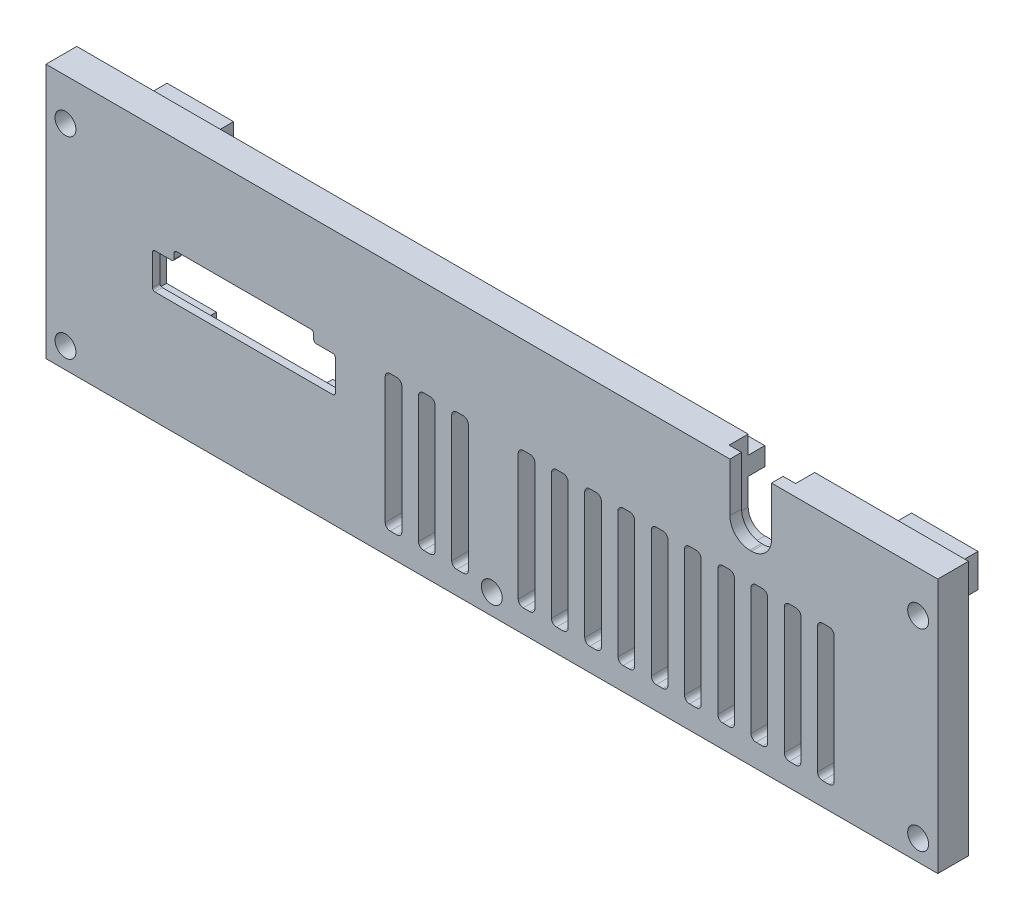
from build123d import *

# Parameters (mm, degrees)
SKETCH1_W                       = 136.2202
SKETCH1_H                       = 38.9636
BOSS_EXTRUDE1_DEPTH             = 4.699
CUT_EXTRUDE1_DEPTH              = 5.699
SKETCH3_W                       = 38.1
SKETCH3_H                       = 21.336
CUT_EXTRUDE3_DEPTH              = 3.556
M3_CLEARANCE_HOLE1_D            = 3.2
M3_CLEARANCE_HOLE1_DEPTH        = 4.826
SKETCH6_W                       = 10.16
SKETCH6_H                       = 5.08
BOSS_EXTRUDE3_DEPTH             = 7.62
BOSS_EXTRUDE3_DEPTH_BACK        = 4.699
SKETCH7_W                       = 109.1438
SKETCH7_H                       = 2.794
BOSS_EXTRUDE4_DEPTH             = 2.54
FILLET1_R                       = 2.54
TAP_DRILL_FOR_M3X0_5_TAP1_D     = 2.5
TAP_DRILL_FOR_M3X0_5_TAP1_DEPTH = 5.08
CUT_EXTRUDE4_DEPTH              = 13.319
CUT_EXTRUDE5_DEPTH              = 5.461
CUT_EXTRUDE8_DEPTH              = 5.699
SKETCH13_W                      = 38.1
SKETCH13_H                      = 21.336
BOSS_EXTRUDE5_DEPTH             = 3.556


with BuildPart() as part:
    # Sketch1 → Boss-Extrude1 (new body)
    with BuildSketch(Plane.XY):
        with Locations((68.1101, 19.4818)):
            Rectangle(SKETCH1_W, SKETCH1_H)
    extrude(amount=BOSS_EXTRUDE1_DEPTH)

    # Sketch2 → Cut-Extrude1 (cut, through all)
    with BuildSketch(Plane.XY.offset(4.699)):
        with BuildLine():
            Line((16.637, 17.152915383), (43.815, 17.152915383))
            ThreePointArc((43.815, 17.152915383), (44.084407684, 17.264507699), (44.196, 17.533915383))
            Line((44.196, 17.533915383), (44.196, 22.232915383))
            ThreePointArc((44.196, 22.232915383), (44.084407684, 22.502323067), (43.815, 22.613915383))
            Line((43.815, 22.613915383), (41.275, 22.613915383))
            ThreePointArc((41.275, 22.613915383), (41.005592316, 22.725507699), (40.894, 22.994915383))
            Line((40.894, 22.994915383), (40.894, 23.756915383))
            ThreePointArc((40.894, 23.756915383), (40.782407684, 24.026323067), (40.513, 24.137915383))
            Line((40.513, 24.137915383), (19.939, 24.137915383))
            ThreePointArc((19.939, 24.137915383), (19.669592316, 24.026323067), (19.558, 23.756915383))
            Line((19.558, 23.756915383), (19.558, 22.994915383))
            ThreePointArc((19.558, 22.994915383), (19.446407684, 22.725507699), (19.177, 22.613915383))
            Line((19.177, 22.613915383), (16.637, 22.613915383))
            ThreePointArc((16.637, 22.613915383), (16.367592316, 22.502323067), (16.256, 22.232915383))
            Line((16.256, 22.232915383), (16.256, 17.533915383))
            ThreePointArc((16.256, 17.533915383), (16.367592316, 17.264507699), (16.637, 17.152915383))
        make_face()
    extrude(amount=-CUT_EXTRUDE1_DEPTH, mode=Mode.SUBTRACT)

    # Sketch3 → Cut-Extrude3 (cut)
    with BuildSketch(Plane(origin=(0, 0, 0), x_dir=(-1, 0, 0), z_dir=(0, 0, -1))):
        with Locations((-30.226, 20.581915383)):
            Rectangle(SKETCH3_W, SKETCH3_H)
    extrude(amount=-CUT_EXTRUDE3_DEPTH, mode=Mode.SUBTRACT)

    # M3 Clearance Hole1
    with Locations(Plane.XY.offset(4.699)):
        with Locations((2.9718, 32.6136), (2.9718, 3.175), (68.0974, 3.175), (133.223, 32.6136), (133.223, 3.175)):
            Hole(M3_CLEARANCE_HOLE1_D / 2, depth=M3_CLEARANCE_HOLE1_DEPTH)

    # Sketch6 → Boss-Extrude3 (add, two sides)
    with BuildSketch(Plane(origin=(0, 0, 0), x_dir=(-1, 0, 0), z_dir=(0, 0, -1))) as boss_extrude3_sk:
        with Locations((-124.968, 30.8356)):
            Rectangle(SKETCH6_W, SKETCH6_H)
        with Locations((-11.2522, 30.8356)):
            Rectangle(SKETCH6_W, SKETCH6_H)
    extrude(amount=BOSS_EXTRUDE3_DEPTH)
    extrude(boss_extrude3_sk.sketch, amount=-BOSS_EXTRUDE3_DEPTH_BACK)

    # Sketch7 → Boss-Extrude4 (add)
    with BuildSketch(Plane(origin=(0, 0, 0), x_dir=(-1, 0, 0), z_dir=(0, 0, -1))):
        with Locations((-68.1101, 34.7726)):
            Rectangle(SKETCH7_W, SKETCH7_H)
    extrude(amount=BOSS_EXTRUDE4_DEPTH)

    # Fillet1
    fillet1_edges = [part.edges().sort_by_distance(p)[0] for p in [
        (14.9352, 33.3756, -2.54),
        (121.285, 33.3756, -2.54),
    ]]
    fillet(fillet1_edges, radius=FILLET1_R)

    # Tap Drill for M3x0.5 Tap1
    with Locations(Plane(origin=(0, 33.3756, 0), x_dir=(1, 0, 0), z_dir=(0, 1, 0))):
        with Locations((126.365, 3.81), (9.8552, 3.81)):
            Hole(TAP_DRILL_FOR_M3X0_5_TAP1_D / 2, depth=TAP_DRILL_FOR_M3X0_5_TAP1_DEPTH)

    # Sketch10 → Cut-Extrude4 (cut, through all)
    with BuildSketch(Plane.XY.offset(4.699)):
        with BuildLine():
            Line((104.4702, 38.9636), (110.8202, 38.9636))
            Line((110.8202, 38.9636), (110.8202, 31.4706))
            ThreePointArc((110.8202, 31.4706), (109.927461469, 29.315338531), (107.7722, 28.4226))
            Line((107.7722, 28.4226), (107.5182, 28.4226))
            ThreePointArc((107.5182, 28.4226), (105.362938531, 29.315338531), (104.4702, 31.4706))
            Line((104.4702, 31.4706), (104.4702, 38.9636))
        make_face()
    extrude(amount=-CUT_EXTRUDE4_DEPTH, mode=Mode.SUBTRACT)

    # Sketch11 → Cut-Extrude5 (cut)
    with BuildSketch(Plane(origin=(0, 0, -2.54), x_dir=(-1, 0, 0), z_dir=(0, 0, -1))):
        with BuildLine():
            Line((-110.1852, 26.7716), (-105.1052, 26.7716))
            ThreePointArc((-105.1052, 26.7716), (-103.309148776, 27.515548776), (-102.5652, 29.3116))
            Line((-102.5652, 29.3116), (-102.5652, 38.9636))
            Line((-102.5652, 38.9636), (-112.7252, 38.9636))
            Line((-112.7252, 38.9636), (-112.7252, 29.3116))
            ThreePointArc((-112.7252, 29.3116), (-111.981251224, 27.515548776), (-110.1852, 26.7716))
        make_face()
    extrude(amount=-CUT_EXTRUDE5_DEPTH, mode=Mode.SUBTRACT)

    # Sketch12 → Cut-Extrude8 (cut, through all)
    with BuildSketch(Plane.XY):
        with BuildLine():
            Line((52.578, 24.324457691), (53.594, 24.324457691))
            ThreePointArc((53.594, 24.324457691), (54.132815367, 24.101273059), (54.356, 23.562457691))
            Line((54.356, 23.562457691), (54.356, 4.258457691))
            ThreePointArc((54.356, 4.258457691), (54.132815367, 3.719642324), (53.594, 3.496457691))
            Line((53.594, 3.496457691), (52.578, 3.496457691))
            ThreePointArc((52.578, 3.496457691), (52.039184633, 3.719642324), (51.816, 4.258457691))
            Line((51.816, 4.258457691), (51.816, 23.562457691))
            ThreePointArc((51.816, 23.562457691), (52.039184633, 24.101273059), (52.578, 24.324457691))
        make_face()
        with BuildLine():
            Line((57.658, 24.324457691), (58.674, 24.324457691))
            ThreePointArc((58.674, 24.324457691), (59.212815367, 24.101273059), (59.436, 23.562457691))
            Line((59.436, 23.562457691), (59.436, 4.258457691))
            ThreePointArc((59.436, 4.258457691), (59.212815367, 3.719642324), (58.674, 3.496457691))
            Line((58.674, 3.496457691), (57.658, 3.496457691))
            ThreePointArc((57.658, 3.496457691), (57.119184633, 3.719642324), (56.896, 4.258457691))
            Line((56.896, 4.258457691), (56.896, 23.562457691))
            ThreePointArc((56.896, 23.562457691), (57.119184633, 24.101273059), (57.658, 24.324457691))
        make_face()
        with BuildLine():
            Line((62.738, 24.324457691), (63.754, 24.324457691))
            ThreePointArc((63.754, 24.324457691), (64.292815367, 24.101273059), (64.516, 23.562457691))
            Line((64.516, 23.562457691), (64.516, 4.258457691))
            ThreePointArc((64.516, 4.258457691), (64.292815367, 3.719642324), (63.754, 3.496457691))
            Line((63.754, 3.496457691), (62.738, 3.496457691))
            ThreePointArc((62.738, 3.496457691), (62.199184633, 3.719642324), (61.976, 4.258457691))
            Line((61.976, 4.258457691), (61.976, 23.562457691))
            ThreePointArc((61.976, 23.562457691), (62.199184633, 24.101273059), (62.738, 24.324457691))
        make_face()
        with BuildLine():
            Line((72.898, 24.324457691), (73.914, 24.324457691))
            ThreePointArc((73.914, 24.324457691), (74.452815367, 24.101273059), (74.676, 23.562457691))
            Line((74.676, 23.562457691), (74.676, 4.258457691))
            ThreePointArc((74.676, 4.258457691), (74.452815367, 3.719642324), (73.914, 3.496457691))
            Line((73.914, 3.496457691), (72.898, 3.496457691))
            ThreePointArc((72.898, 3.496457691), (72.359184633, 3.719642324), (72.136, 4.258457691))
            Line((72.136, 4.258457691), (72.136, 23.562457691))
            ThreePointArc((72.136, 23.562457691), (72.359184633, 24.101273059), (72.898, 24.324457691))
        make_face()
        with BuildLine():
            Line((77.978, 24.324457691), (78.994, 24.324457691))
            ThreePointArc((78.994, 24.324457691), (79.532815367, 24.101273059), (79.756, 23.562457691))
            Line((79.756, 23.562457691), (79.756, 4.258457691))
            ThreePointArc((79.756, 4.258457691), (79.532815367, 3.719642324), (78.994, 3.496457691))
            Line((78.994, 3.496457691), (77.978, 3.496457691))
            ThreePointArc((77.978, 3.496457691), (77.439184633, 3.719642324), (77.216, 4.258457691))
            Line((77.216, 4.258457691), (77.216, 23.562457691))
            ThreePointArc((77.216, 23.562457691), (77.439184633, 24.101273059), (77.978, 24.324457691))
        make_face()
        with BuildLine():
            Line((83.058, 24.324457691), (84.074, 24.324457691))
            ThreePointArc((84.074, 24.324457691), (84.612815367, 24.101273059), (84.836, 23.562457691))
            Line((84.836, 23.562457691), (84.836, 4.258457691))
            ThreePointArc((84.836, 4.258457691), (84.612815367, 3.719642324), (84.074, 3.496457691))
            Line((84.074, 3.496457691), (83.058, 3.496457691))
            ThreePointArc((83.058, 3.496457691), (82.519184633, 3.719642324), (82.296, 4.258457691))
            Line((82.296, 4.258457691), (82.296, 23.562457691))
            ThreePointArc((82.296, 23.562457691), (82.519184633, 24.101273059), (83.058, 24.324457691))
        make_face()
        with BuildLine():
            Line((88.138, 24.324457691), (89.154, 24.324457691))
            ThreePointArc((89.154, 24.324457691), (89.692815367, 24.101273059), (89.916, 23.562457691))
            Line((89.916, 23.562457691), (89.916, 4.258457691))
            ThreePointArc((89.916, 4.258457691), (89.692815367, 3.719642324), (89.154, 3.496457691))
            Line((89.154, 3.496457691), (88.138, 3.496457691))
            ThreePointArc((88.138, 3.496457691), (87.599184633, 3.719642324), (87.376, 4.258457691))
            Line((87.376, 4.258457691), (87.376, 23.562457691))
            ThreePointArc((87.376, 23.562457691), (87.599184633, 24.101273059), (88.138, 24.324457691))
        make_face()
        with BuildLine():
            Line((93.218, 24.324457691), (94.234, 24.324457691))
            ThreePointArc((94.234, 24.324457691), (94.772815367, 24.101273059), (94.996, 23.562457691))
            Line((94.996, 23.562457691), (94.996, 4.258457691))
            ThreePointArc((94.996, 4.258457691), (94.772815367, 3.719642324), (94.234, 3.496457691))
            Line((94.234, 3.496457691), (93.218, 3.496457691))
            ThreePointArc((93.218, 3.496457691), (92.679184633, 3.719642324), (92.456, 4.258457691))
            Line((92.456, 4.258457691), (92.456, 23.562457691))
            ThreePointArc((92.456, 23.562457691), (92.679184633, 24.101273059), (93.218, 24.324457691))
        make_face()
        with BuildLine():
            Line((98.298, 24.324457691), (99.314, 24.324457691))
            ThreePointArc((99.314, 24.324457691), (99.852815367, 24.101273059), (100.076, 23.562457691))
            Line((100.076, 23.562457691), (100.076, 4.258457691))
            ThreePointArc((100.076, 4.258457691), (99.852815367, 3.719642324), (99.314, 3.496457691))
            Line((99.314, 3.496457691), (98.298, 3.496457691))
            ThreePointArc((98.298, 3.496457691), (97.759184633, 3.719642324), (97.536, 4.258457691))
            Line((97.536, 4.258457691), (97.536, 23.562457691))
            ThreePointArc((97.536, 23.562457691), (97.759184633, 24.101273059), (98.298, 24.324457691))
        make_face()
        with BuildLine():
            Line((103.378, 24.324457691), (104.394, 24.324457691))
            ThreePointArc((104.394, 24.324457691), (104.932815367, 24.101273059), (105.156, 23.562457691))
            Line((105.156, 23.562457691), (105.156, 4.258457691))
            ThreePointArc((105.156, 4.258457691), (104.932815367, 3.719642324), (104.394, 3.496457691))
            Line((104.394, 3.496457691), (103.378, 3.496457691))
            ThreePointArc((103.378, 3.496457691), (102.839184633, 3.719642324), (102.616, 4.258457691))
            Line((102.616, 4.258457691), (102.616, 23.562457691))
            ThreePointArc((102.616, 23.562457691), (102.839184633, 24.101273059), (103.378, 24.324457691))
        make_face()
        with BuildLine():
            Line((108.458, 24.324457691), (109.474, 24.324457691))
            ThreePointArc((109.474, 24.324457691), (110.012815367, 24.101273059), (110.236, 23.562457691))
            Line((110.236, 23.562457691), (110.236, 4.258457691))
            ThreePointArc((110.236, 4.258457691), (110.012815367, 3.719642324), (109.474, 3.496457691))
            Line((109.474, 3.496457691), (108.458, 3.496457691))
            ThreePointArc((108.458, 3.496457691), (107.919184633, 3.719642324), (107.696, 4.258457691))
            Line((107.696, 4.258457691), (107.696, 23.562457691))
            ThreePointArc((107.696, 23.562457691), (107.919184633, 24.101273059), (108.458, 24.324457691))
        make_face()
        with BuildLine():
            Line((113.538, 24.324457691), (114.554, 24.324457691))
            ThreePointArc((114.554, 24.324457691), (115.092815367, 24.101273059), (115.316, 23.562457691))
            Line((115.316, 23.562457691), (115.316, 4.258457691))
            ThreePointArc((115.316, 4.258457691), (115.092815367, 3.719642324), (114.554, 3.496457691))
            Line((114.554, 3.496457691), (113.538, 3.496457691))
            ThreePointArc((113.538, 3.496457691), (112.999184633, 3.719642324), (112.776, 4.258457691))
            Line((112.776, 4.258457691), (112.776, 23.562457691))
            ThreePointArc((112.776, 23.562457691), (112.999184633, 24.101273059), (113.538, 24.324457691))
        make_face()
        with BuildLine():
            Line((118.618, 24.324457691), (119.634, 24.324457691))
            ThreePointArc((119.634, 24.324457691), (120.172815367, 24.101273059), (120.396, 23.562457691))
            Line((120.396, 23.562457691), (120.396, 4.258457691))
            ThreePointArc((120.396, 4.258457691), (120.172815367, 3.719642324), (119.634, 3.496457691))
            Line((119.634, 3.496457691), (118.618, 3.496457691))
            ThreePointArc((118.618, 3.496457691), (118.079184633, 3.719642324), (117.856, 4.258457691))
            Line((117.856, 4.258457691), (117.856, 23.562457691))
            ThreePointArc((117.856, 23.562457691), (118.079184633, 24.101273059), (118.618, 24.324457691))
        make_face()
    extrude(amount=CUT_EXTRUDE8_DEPTH, mode=Mode.SUBTRACT)

    # Sketch13 → Boss-Extrude5 (add)
    with BuildSketch(Plane(origin=(0, 0, 3.556), x_dir=(-1, 0, 0), z_dir=(0, 0, -1))):
        with Locations((-30.226, 20.581915383)):
            Rectangle(SKETCH13_W, SKETCH13_H)
        Polygon((-39.116, 26.677915383), (-39.116, 30.360915383), (-21.336, 30.360915383), (-21.336, 26.677915383), (-13.716, 26.677915383), (-13.716, 14.485915383), (-21.336, 14.485915383), (-21.336, 10.802915383), (-39.116, 10.802915383), (-39.116, 14.485915383), (-46.736, 14.485915383), (-46.736, 26.677915383), align=None, mode=Mode.SUBTRACT)
    extrude(amount=BOSS_EXTRUDE5_DEPTH)


solid = part.part
